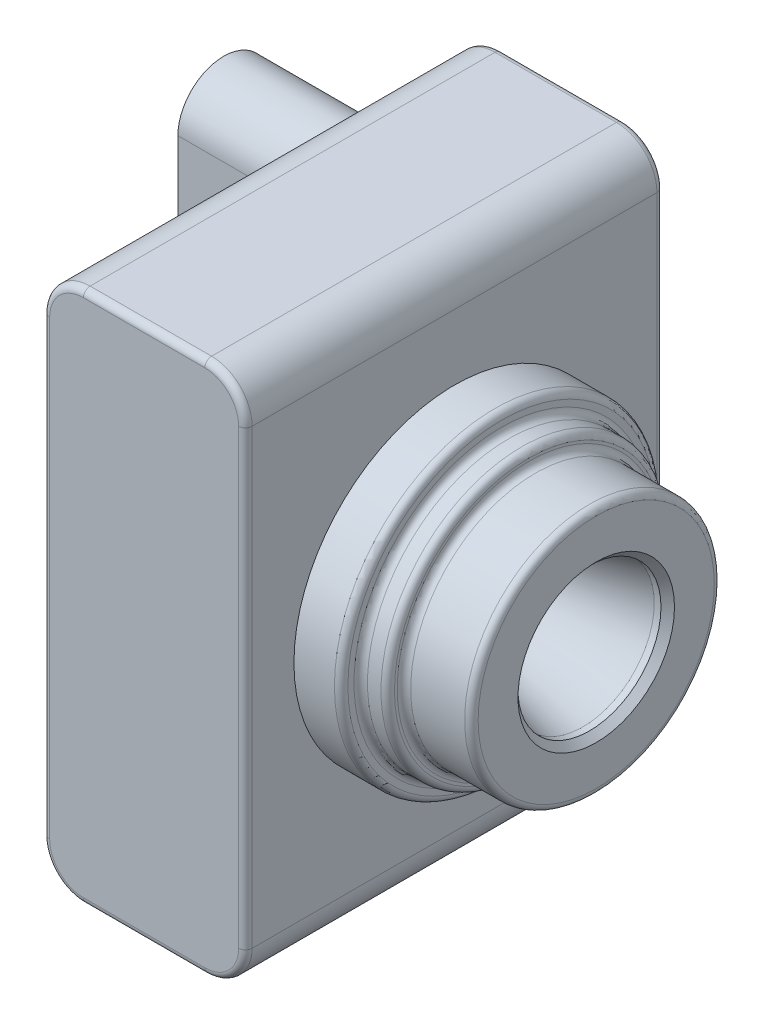
from build123d import *

# Parameters (mm, degrees)
BOSS_EXTRUDE1_DEPTH = 31
SKETCH2_R           = 11.9
BOSS_EXTRUDE2_DEPTH = 3.5
SKETCH3_R           = 10.45
BOSS_EXTRUDE3_DEPTH = 2
SKETCH4_R           = 9.25
BOSS_EXTRUDE4_DEPTH = 5
SKETCH5_R           = 5.3
CUT_EXTRUDE1_DEPTH  = 17
FILLET2_R           = 0.5
FILLET3_R           = 0.5
CHAMFER1_SIZE       = 0.5
SKETCH6_R           = 1.154157684
CUT_EXTRUDE2_DEPTH  = 2
CHAMFER4_SIZE       = 16
CHAMFER4_SIZE2      = 3.989248045
BOSS_EXTRUDE5_DEPTH = 10
FILLET4_R           = 0.5


with BuildPart() as part:
    # Sketch1 → Boss-Extrude1 (new body)
    with BuildSketch(Plane.XY):
        with BuildLine():
            Line((-4.5, -19.75), (4.5, -19.75))
            ThreePointArc((4.5, -19.75), (6.621320344, -18.871320344), (7.5, -16.75))
            Line((7.5, -16.75), (7.5, 16.75))
            ThreePointArc((7.5, 16.75), (6.621320344, 18.871320344), (4.5, 19.75))
            Line((4.5, 19.75), (-4.5, 19.75))
            ThreePointArc((-4.5, 19.75), (-6.621320344, 18.871320344), (-7.5, 16.75))
            Line((-7.5, 16.75), (-7.5, -16.75))
            ThreePointArc((-7.5, -16.75), (-6.621320344, -18.871320344), (-4.5, -19.75))
        make_face()
    extrude(amount=BOSS_EXTRUDE1_DEPTH)

    # Sketch2 → Boss-Extrude2 (add)
    with BuildSketch(Plane(origin=(7.5, 0, 0), x_dir=(0, 0, -1), z_dir=(1, 0, 0))):
        with Locations((-15.5, 0)):
            Circle(SKETCH2_R)
    extrude(amount=BOSS_EXTRUDE2_DEPTH)

    # Sketch3 → Boss-Extrude3 (add)
    with BuildSketch(Plane(origin=(11, 0, 0), x_dir=(0, 0, -1), z_dir=(1, 0, 0))):
        with Locations((-15.5, 0)):
            Circle(SKETCH3_R)
    extrude(amount=BOSS_EXTRUDE3_DEPTH)

    # Sketch4 → Boss-Extrude4 (add)
    with BuildSketch(Plane(origin=(13, 0, 0), x_dir=(0, 0, -1), z_dir=(1, 0, 0))):
        with Locations((-15.5, 0)):
            Circle(SKETCH4_R)
    extrude(amount=BOSS_EXTRUDE4_DEPTH)

    # Sketch5 → Cut-Extrude1 (cut)
    with BuildSketch(Plane(origin=(18, 0, 0), x_dir=(0, 0, -1), z_dir=(1, 0, 0))):
        with Locations((-15.5, 0)):
            Circle(SKETCH5_R)
    extrude(amount=-CUT_EXTRUDE1_DEPTH, mode=Mode.SUBTRACT)

    # Fillet2
    fillet2_edges = [part.edges().sort_by_distance(p)[0] for p in [
        (11, 0, 25.95),
        (13, 0, 24.75),
    ]]
    fillet(fillet2_edges, radius=FILLET2_R)

    # Fillet3
    fillet3_edges = [part.edges().sort_by_distance(p)[0] for p in [
        (11, 0, 27.4),
        (13, 0, 25.95),
        (18, 0, 24.75),
    ]]
    fillet(fillet3_edges, radius=FILLET3_R)

    # Chamfer1
    chamfer1_edges = [part.edges().sort_by_distance(p)[0] for p in [
        (18, 0, 20.8),
    ]]
    chamfer(chamfer1_edges, length=CHAMFER1_SIZE)

    # Sketch6 → Cut-Extrude2 (cut)
    with BuildSketch(Plane(origin=(1, 0, 0), x_dir=(0, 0, -1), z_dir=(1, 0, 0))):
        with Locations((-15.5, 0)):
            Circle(SKETCH6_R)
    extrude(amount=-CUT_EXTRUDE2_DEPTH, mode=Mode.SUBTRACT)

    # Chamfer4
    chamfer4_edges = [part.edges().sort_by_distance(p)[0] for p in [
        (1, 0, 20.8),
    ]]
    chamfer4_side = [part.faces().sort_by_distance(p)[0] for p in [
        (9.25, 0, 20.8),
    ]]
    chamfer(chamfer4_edges, length=CHAMFER4_SIZE, length2=CHAMFER4_SIZE2, reference=chamfer4_side[0])

    # Sketch7 → Boss-Extrude5 (add)
    with BuildSketch(Plane.ZY.offset(7.5)):
        with BuildLine():
            Line((11, 13.15), (11, -11.85))
            Line((11, -11.85), (4.2, -11.85))
            Line((4.2, -11.85), (4.2, 13.15))
            ThreePointArc((4.2, 13.15), (7.6, 16.55), (11, 13.15))
        make_face()
    extrude(amount=BOSS_EXTRUDE5_DEPTH)

    # Fillet4
    fillet4_edges = [part.edges().sort_by_distance(p)[0] for p in [
        (6.621320344, 18.871320344, 31),
        (7.5, 0, 0),
        (6.621320344, -18.871320344, 0),
        (0, 19.75, 31),
        (-6.621320344, 18.871320344, 31),
        (-7.5, 0, 31),
        (-6.621320344, -18.871320344, 31),
        (0, -19.75, 31),
        (6.621320344, -18.871320344, 31),
        (7.5, 0, 31),
        (0, -19.75, 0),
        (-6.621320344, -18.871320344, 0),
        (-7.5, 0, 0),
        (-6.621320344, 18.871320344, 0),
        (0, 19.75, 0),
        (6.621320344, 18.871320344, 0),
    ]]
    fillet(fillet4_edges, radius=FILLET4_R)


solid = part.part
